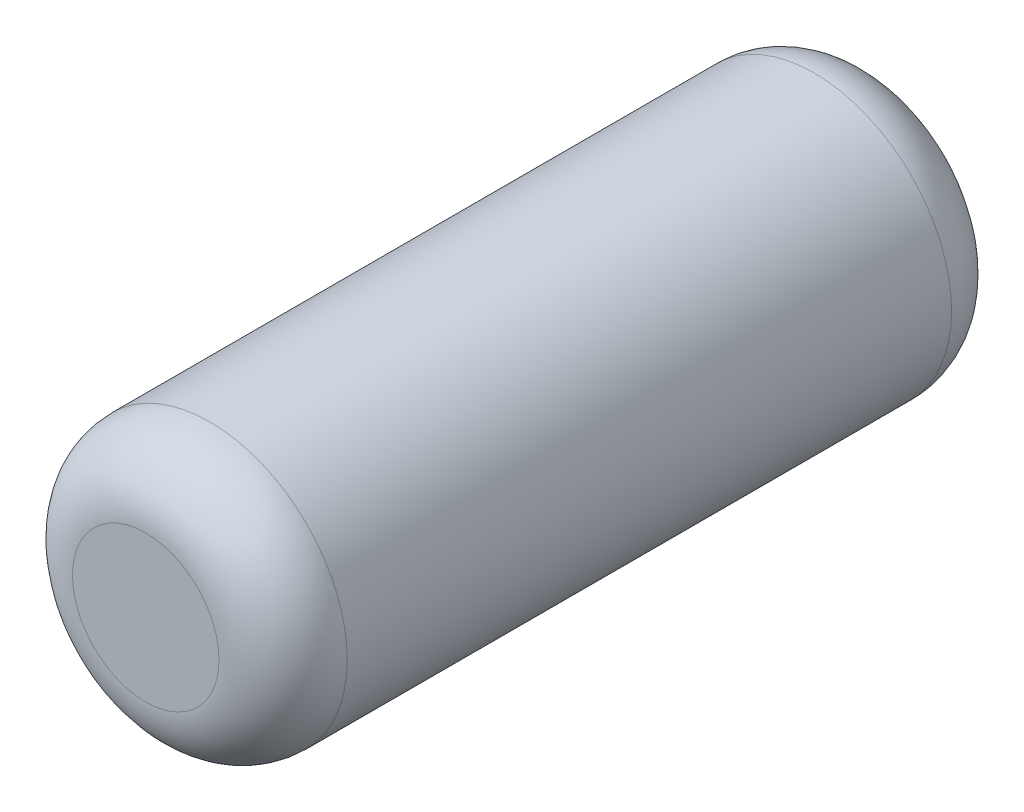
from build123d import *

# Parameters (mm, degrees)
SKETCH1_R           = 0.75
BOSS_EXTRUDE1_DEPTH = 2
FILLET1_R           = 0.35


with BuildPart() as part:
    # Sketch1 → Boss-Extrude1 (new body, symmetric)
    with BuildSketch(Plane.XY):
        Circle(SKETCH1_R)
    extrude(amount=BOSS_EXTRUDE1_DEPTH, both=True)

    # Fillet1
    fillet1_edges = [part.edges().sort_by_distance(p)[0] for p in [
        (-0.75, 0, -2),
        (-0.75, 0, 2),
    ]]
    fillet(fillet1_edges, radius=FILLET1_R)


solid = part.part
